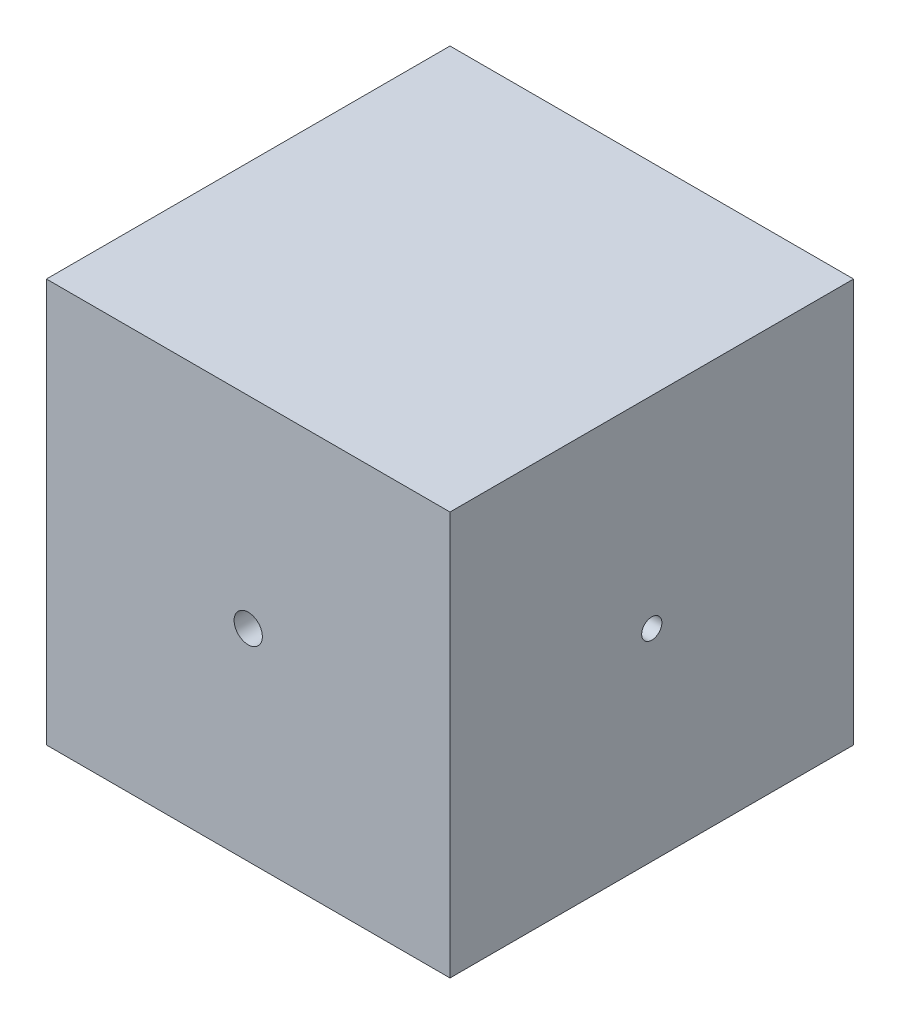
from build123d import *

# Parameters (mm, degrees)
SKETCH1_W                       = 100
SKETCH1_H                       = 100
BOSS_EXTRUDE1_DEPTH             = 50
M8X1_25_TAPPED_HOLE1_D          = 6.8
M8X1_25_TAPPED_HOLE1_DEPTH      = 27.75
M8X1_25_TAPPED_HOLE1_TIP        = 2.042926105
M8X1_0_TAPPED_HOLE1_D           = 7
M8X1_0_TAPPED_HOLE1_DEPTH       = 19
M8X1_0_TAPPED_HOLE1_TIP         = 2.103012167
M6X1_0_TAPPED_HOLE1_D           = 5
M6X1_0_TAPPED_HOLE1_DEPTH       = 15
M6X1_0_TAPPED_HOLE1_TIP         = 1.502151548
CBORE_FOR_M12_SHCS1_D           = 13.5
CBORE_FOR_M12_SHCS1_DEPTH       = 35
CBORE_FOR_M12_SHCS1_CBORE_D     = 20
CBORE_FOR_M12_SHCS1_CBORE_DEPTH = 12
CBORE_FOR_M12_SHCS1_TIP         = 4.055809178


with BuildPart() as part:
    # Sketch1 → Boss-Extrude1 (new body, symmetric)
    with BuildSketch(Plane.XY):
        Rectangle(SKETCH1_W, SKETCH1_H)
    extrude(amount=BOSS_EXTRUDE1_DEPTH, both=True)

    # M8x1.25 Tapped Hole1
    with Locations(Plane.ZY.offset(50)):
        with Locations((0, 0)):
            Hole(M8X1_25_TAPPED_HOLE1_D / 2, depth=M8X1_25_TAPPED_HOLE1_DEPTH)
            with Locations((0, 0, -(M8X1_25_TAPPED_HOLE1_DEPTH + M8X1_25_TAPPED_HOLE1_TIP / 2))):  # 118° drill point
                Cone(0, M8X1_25_TAPPED_HOLE1_D / 2, M8X1_25_TAPPED_HOLE1_TIP, mode=Mode.SUBTRACT)

    # M8x1.0 Tapped Hole1
    with Locations(Plane.XY.offset(50)):
        with Locations((0, 0)):
            Hole(M8X1_0_TAPPED_HOLE1_D / 2, depth=M8X1_0_TAPPED_HOLE1_DEPTH)
            with Locations((0, 0, -(M8X1_0_TAPPED_HOLE1_DEPTH + M8X1_0_TAPPED_HOLE1_TIP / 2))):  # 118° drill point
                Cone(0, M8X1_0_TAPPED_HOLE1_D / 2, M8X1_0_TAPPED_HOLE1_TIP, mode=Mode.SUBTRACT)

    # M6x1.0 Tapped Hole1
    with Locations(Plane(origin=(50, 0, 0), x_dir=(0, 0, -1), z_dir=(1, 0, 0))):
        with Locations((0, 0)):
            Hole(M6X1_0_TAPPED_HOLE1_D / 2, depth=M6X1_0_TAPPED_HOLE1_DEPTH)
            with Locations((0, 0, -(M6X1_0_TAPPED_HOLE1_DEPTH + M6X1_0_TAPPED_HOLE1_TIP / 2))):  # 118° drill point
                Cone(0, M6X1_0_TAPPED_HOLE1_D / 2, M6X1_0_TAPPED_HOLE1_TIP, mode=Mode.SUBTRACT)

    # CBORE for M12 SHCS1
    with Locations(Plane(origin=(0, 0, -50), x_dir=(-1, 0, 0), z_dir=(0, 0, -1))):
        with Locations((0, 0)):
            CounterBoreHole(CBORE_FOR_M12_SHCS1_D / 2, CBORE_FOR_M12_SHCS1_CBORE_D / 2, CBORE_FOR_M12_SHCS1_CBORE_DEPTH, depth=CBORE_FOR_M12_SHCS1_DEPTH)
            with Locations((0, 0, -(CBORE_FOR_M12_SHCS1_DEPTH + CBORE_FOR_M12_SHCS1_TIP / 2))):  # 118° drill point
                Cone(0, CBORE_FOR_M12_SHCS1_D / 2, CBORE_FOR_M12_SHCS1_TIP, mode=Mode.SUBTRACT)


solid = part.part
